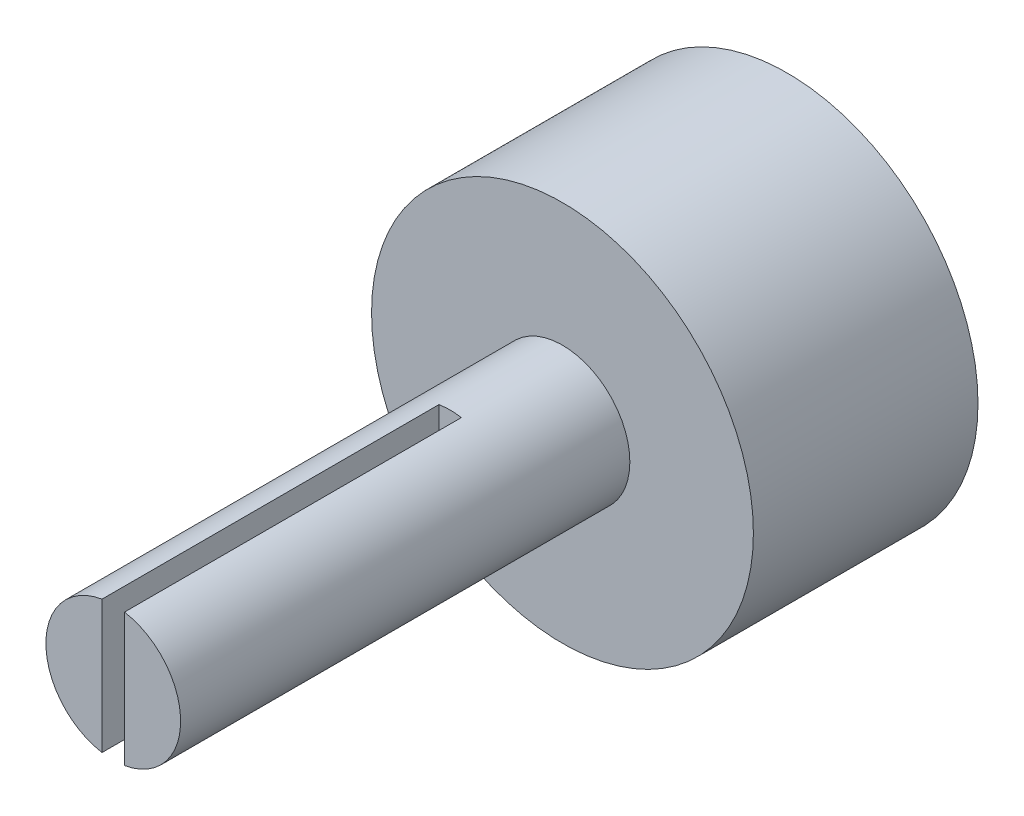
from build123d import *

# Parameters (mm, degrees)
SKETCH1_R               = 3
BOSS_EXTRUDE1_DEPTH     = 20
SKETCH1_3_R             = 8.5
BOSS_EXTRUDE2_DEPTH     = 10
CUT_EXTRUDE1_DEPTH      = 0.5
CUT_EXTRUDE1_DEPTH_BACK = 0.5
SKETCH2_W               = 15
SKETCH2_H               = 6


with BuildPart() as part:
    # Sketch1 → Boss-Extrude1 (new body)
    with BuildSketch(Plane.XY):
        Circle(SKETCH1_R)
    extrude(amount=BOSS_EXTRUDE1_DEPTH)

    # Sketch1_3 → Boss-Extrude2 (add)
    with BuildSketch(Plane.XY):
        Circle(SKETCH1_3_R)
    extrude(amount=-BOSS_EXTRUDE2_DEPTH)

    # Sketch2 → Cut-Extrude1 (cut, two sides: drawn at the far end of the back side and taken through both)
    with BuildSketch(Plane(origin=(0, 0, 0), x_dir=(0, 0, -1), z_dir=(1, 0, 0)).offset(-CUT_EXTRUDE1_DEPTH_BACK)):
        with Locations((-12.5, 0)):
            Rectangle(SKETCH2_W, SKETCH2_H)
    extrude(amount=CUT_EXTRUDE1_DEPTH + CUT_EXTRUDE1_DEPTH_BACK, mode=Mode.SUBTRACT)


solid = part.part
